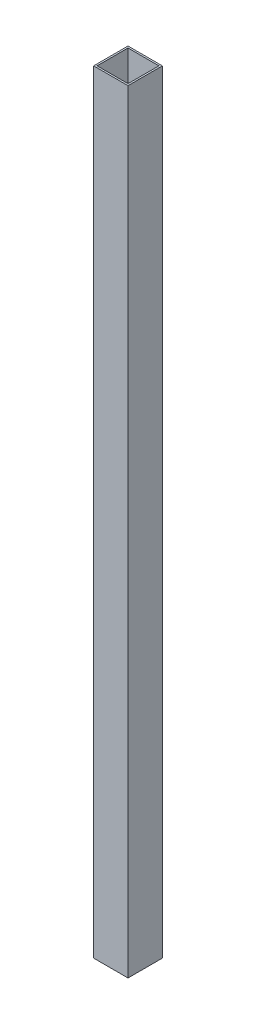
from build123d import *

# Parameters (mm, degrees)
CROQUIS1_W              = 40
CROQUIS1_H              = 40
SALIENTE_EXTRUIR1_DEPTH = 900
CROQUIS2_W              = 36
CROQUIS2_H              = 36
CORTAR_EXTRUIR1_DEPTH   = 901


with BuildPart() as part:
    # Croquis1 → Saliente-Extruir1 (new body)
    with BuildSketch(Plane(origin=(0, 0, 0), x_dir=(1, 0, 0), z_dir=(0, 1, 0))):
        Rectangle(CROQUIS1_W, CROQUIS1_H)
    extrude(amount=SALIENTE_EXTRUIR1_DEPTH)

    # Croquis2 → Cortar-Extruir1 (cut, through all)
    with BuildSketch(Plane(origin=(0, 900, 0), x_dir=(1, 0, 0), z_dir=(0, 1, 0))):
        Rectangle(CROQUIS2_W, CROQUIS2_H)
    extrude(amount=-CORTAR_EXTRUIR1_DEPTH, mode=Mode.SUBTRACT)


solid = part.part
